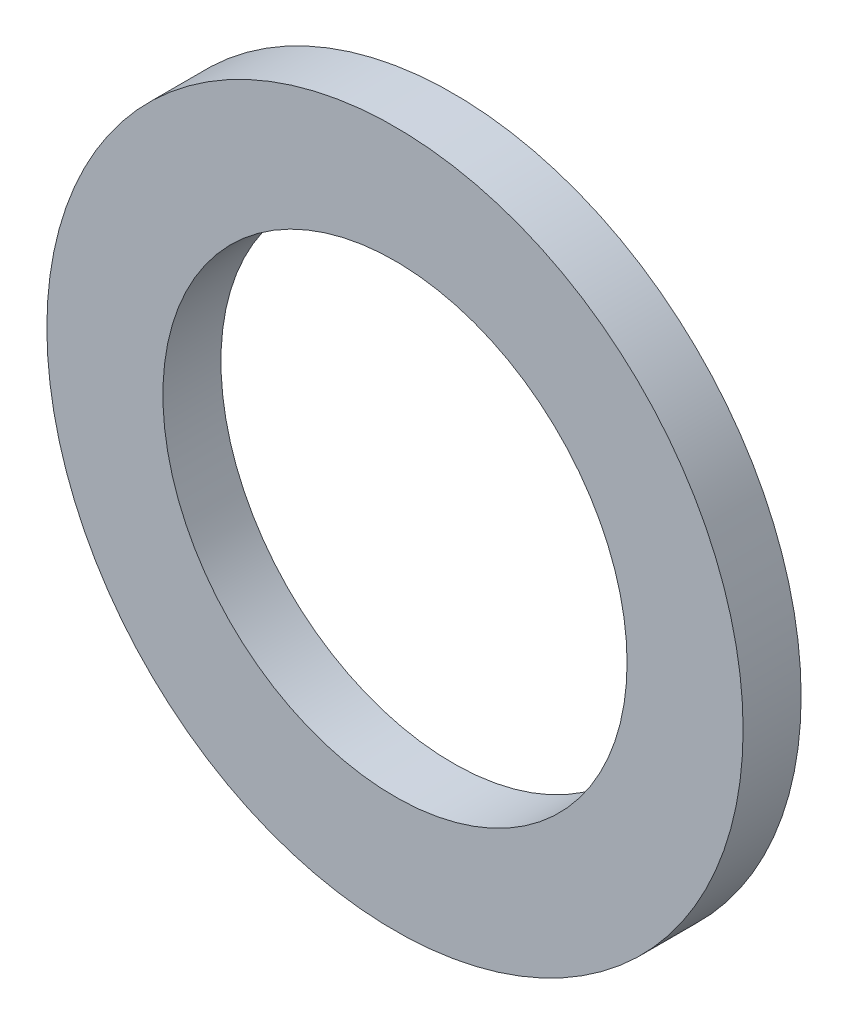
from build123d import *

# Parameters (mm, degrees)
ESQUISSE1_R      = 6
ESQUISSE1_R_2    = 4
EXTRUSION1_DEPTH = 1


with BuildPart() as part:
    # Esquisse1 → Extrusion1 (new body)
    with BuildSketch(Plane.XY):
        Circle(ESQUISSE1_R)
        Circle(ESQUISSE1_R_2, mode=Mode.SUBTRACT)
    extrude(amount=EXTRUSION1_DEPTH)


solid = part.part
